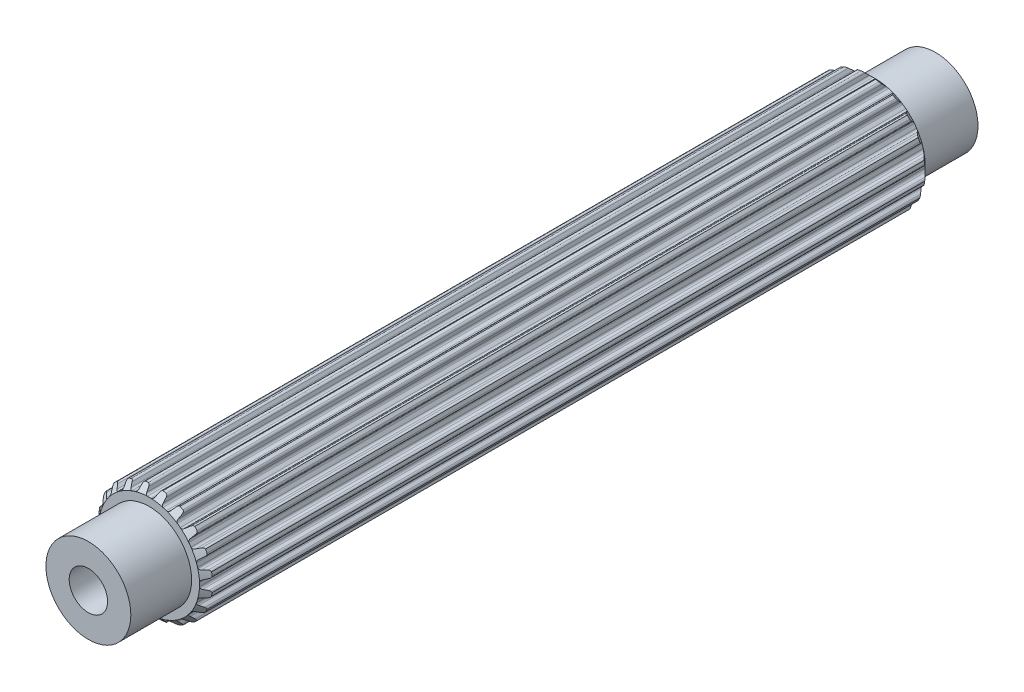
from build123d import *

# Parameters (mm, degrees)
BOSS_EXTRUDE1_DEPTH            = 21.37918
SKETCH2_R                      = 2.5019
BOSS_EXTRUDE2_DEPTH            = 24.96058
CUT_EXTRUDE1_REACH             = 26.961
SKETCH6_R                      = 1.1303
CUT_EXTRUDE1_DIRECTION_2_REACH = 26.961
SKETCH7_R                      = 1.1303
BOSS_EXTRUDE3_DEPTH            = 15.43558
BOSS_EXTRUDE3_DEPTH_BACK       = 15.43558


with BuildPart() as part:
    # Sketch1 → Boss-Extrude1 (new body, symmetric)
    with BuildSketch(Plane.XY):
        with BuildLine():
            Line((-0.106949245, 2.969874934), (0.106949245, 2.969874934))
            ThreePointArc((0.106949245, 2.969874934), (0.196343213, 2.986924176), (0.253739238, 3.057547504))
            Line((0.253739238, 3.057547504), (0.315888147, 3.237526941))
            ThreePointArc((0.315888147, 3.237526941), (0.359032156, 3.298322911), (0.4281449, 3.326269005))
            Line((0.4281449, 3.326269005), (0.620027588, 3.2937547))
            ThreePointArc((0.620027588, 3.2937547), (0.689621142, 3.24802576), (0.718272212, 3.169836791))
            Line((0.718272212, 3.169836791), (0.724389167, 2.979527391))
            ThreePointArc((0.724389167, 2.979527391), (0.750934762, 2.9040661), (0.816027049, 2.857568043))
            Line((0.816027049, 2.857568043), (1.019456602, 2.791469774))
            ThreePointArc((1.019456602, 2.791469774), (1.109743823, 2.780060312), (1.186154496, 2.829490741))
            Line((1.186154496, 2.829490741), (1.300878326, 2.981456288))
            ThreePointArc((1.300878326, 2.981456288), (1.360697704, 3.02594446), (1.435063648, 3.031165762))
            Line((1.435063648, 3.031165762), (1.607507455, 2.940947809))
            ThreePointArc((1.607507455, 2.940947809), (1.659563839, 2.875951412), (1.662650905, 2.792735615))
            Line((1.662650905, 2.792735615), (1.609659636, 2.609850378))
            ThreePointArc((1.609659636, 2.609850378), (1.611587176, 2.529879385), (1.659124931, 2.465542482))
            Line((1.659124931, 2.465542482), (1.832172444, 2.339816104))
            ThreePointArc((1.832172444, 2.339816104), (1.914514976, 2.301064775), (2.002460687, 2.32446371))
            Line((2.002460687, 2.32446371), (2.158529469, 2.433539921))
            ThreePointArc((2.158529469, 2.433539921), (2.229168681, 2.457365482), (2.301508367, 2.439350895))
            Line((2.301508367, 2.439350895), (2.437633293, 2.300260456))
            ThreePointArc((2.437633293, 2.300260456), (2.467056864, 2.222358901), (2.444277744, 2.14226202))
            Line((2.444277744, 2.14226202), (2.337365406, 1.984703026))
            ThreePointArc((2.337365406, 1.984703026), (2.314486209, 1.908050449), (2.339816104, 1.832172444))
            Line((2.339816104, 1.832172444), (2.465542482, 1.659124931))
            ThreePointArc((2.465542482, 1.659124931), (2.531880064, 1.596824985), (2.622752074, 1.591901975))
            Line((2.622752074, 1.591901975), (2.804888709, 1.64741171))
            ThreePointArc((2.804888709, 1.64741171), (2.879433095, 1.648242449), (2.942665411, 1.608755366))
            Line((2.942665411, 1.608755366), (3.0291466, 1.434407582))
            ThreePointArc((3.0291466, 1.434407582), (3.033057175, 1.351226417), (2.986641646, 1.282088892))
            Line((2.986641646, 1.282088892), (2.836273564, 1.165279113))
            ThreePointArc((2.836273564, 1.165279113), (2.790827206, 1.099448241), (2.791469774, 1.019456602))
            Line((2.791469774, 1.019456602), (2.857568043, 0.816027049))
            ThreePointArc((2.857568043, 0.816027049), (2.901407091, 0.736276839), (2.986310214, 0.703513784))
            Line((2.986310214, 0.703513784), (3.1766859, 0.700023363))
            ThreePointArc((3.1766859, 0.700023363), (3.247838536, 0.677777961), (3.295773863, 0.620683653))
            Line((3.295773863, 0.620683653), (3.324145932, 0.4281449))
            ThreePointArc((3.324145932, 0.4281449), (3.302160717, 0.347826477), (3.236652255, 0.29641597))
            Line((3.236652255, 0.29641597), (3.057547504, 0.231789562))
            ThreePointArc((3.057547504, 0.231789562), (2.993982591, 0.183224379), (2.969874934, 0.106949245))
            Line((2.969874934, 0.106949245), (2.969874934, -0.106949245))
            ThreePointArc((2.969874934, -0.106949245), (2.986924176, -0.196343213), (3.057547504, -0.253739238))
            Line((3.057547504, -0.253739238), (3.237526941, -0.315888147))
            ThreePointArc((3.237526941, -0.315888147), (3.298322911, -0.359032156), (3.326269005, -0.4281449))
            Line((3.326269005, -0.4281449), (3.2937547, -0.620027588))
            ThreePointArc((3.2937547, -0.620027588), (3.24802576, -0.689621142), (3.169836791, -0.718272212))
            Line((3.169836791, -0.718272212), (2.979527391, -0.724389167))
            ThreePointArc((2.979527391, -0.724389167), (2.9040661, -0.750934762), (2.857568043, -0.816027049))
            Line((2.857568043, -0.816027049), (2.791469774, -1.019456602))
            ThreePointArc((2.791469774, -1.019456602), (2.780060312, -1.109743823), (2.829490741, -1.186154496))
            Line((2.829490741, -1.186154496), (2.981456288, -1.300878326))
            ThreePointArc((2.981456288, -1.300878326), (3.02594446, -1.360697704), (3.031165762, -1.435063648))
            Line((3.031165762, -1.435063648), (2.940947809, -1.607507455))
            ThreePointArc((2.940947809, -1.607507455), (2.875951412, -1.659563839), (2.792735615, -1.662650905))
            Line((2.792735615, -1.662650905), (2.609850378, -1.609659636))
            ThreePointArc((2.609850378, -1.609659636), (2.529879385, -1.611587176), (2.465542482, -1.659124931))
            Line((2.465542482, -1.659124931), (2.339816104, -1.832172444))
            ThreePointArc((2.339816104, -1.832172444), (2.301064775, -1.914514976), (2.32446371, -2.002460687))
            Line((2.32446371, -2.002460687), (2.433539921, -2.158529469))
            ThreePointArc((2.433539921, -2.158529469), (2.457365482, -2.229168681), (2.439350895, -2.301508367))
            Line((2.439350895, -2.301508367), (2.300260456, -2.437633293))
            ThreePointArc((2.300260456, -2.437633293), (2.222358901, -2.467056864), (2.14226202, -2.444277744))
            Line((2.14226202, -2.444277744), (1.984703026, -2.337365406))
            ThreePointArc((1.984703026, -2.337365406), (1.908050449, -2.314486209), (1.832172444, -2.339816104))
            Line((1.832172444, -2.339816104), (1.659124931, -2.465542482))
            ThreePointArc((1.659124931, -2.465542482), (1.596824985, -2.531880064), (1.591901975, -2.622752074))
            Line((1.591901975, -2.622752074), (1.64741171, -2.804888709))
            ThreePointArc((1.64741171, -2.804888709), (1.648242449, -2.879433095), (1.608755366, -2.942665411))
            Line((1.608755366, -2.942665411), (1.434407582, -3.0291466))
            ThreePointArc((1.434407582, -3.0291466), (1.351226417, -3.033057175), (1.282088892, -2.986641646))
            Line((1.282088892, -2.986641646), (1.165279113, -2.836273564))
            ThreePointArc((1.165279113, -2.836273564), (1.099448241, -2.790827206), (1.019456602, -2.791469774))
            Line((1.019456602, -2.791469774), (0.816027049, -2.857568043))
            ThreePointArc((0.816027049, -2.857568043), (0.736276839, -2.901407091), (0.703513784, -2.986310214))
            Line((0.703513784, -2.986310214), (0.700023363, -3.1766859))
            ThreePointArc((0.700023363, -3.1766859), (0.677777961, -3.247838536), (0.620683653, -3.295773863))
            Line((0.620683653, -3.295773863), (0.4281449, -3.324145932))
            ThreePointArc((0.4281449, -3.324145932), (0.347826477, -3.302160717), (0.29641597, -3.236652255))
            Line((0.29641597, -3.236652255), (0.231789562, -3.057547504))
            ThreePointArc((0.231789562, -3.057547504), (0.183224379, -2.993982591), (0.106949245, -2.969874934))
            Line((0.106949245, -2.969874934), (-0.106949245, -2.969874934))
            ThreePointArc((-0.106949245, -2.969874934), (-0.196343213, -2.986924176), (-0.253739238, -3.057547504))
            Line((-0.253739238, -3.057547504), (-0.315888147, -3.237526941))
            ThreePointArc((-0.315888147, -3.237526941), (-0.359032156, -3.298322911), (-0.4281449, -3.326269005))
            Line((-0.4281449, -3.326269005), (-0.620027588, -3.2937547))
            ThreePointArc((-0.620027588, -3.2937547), (-0.689621142, -3.24802576), (-0.718272212, -3.169836791))
            Line((-0.718272212, -3.169836791), (-0.724389167, -2.979527391))
            ThreePointArc((-0.724389167, -2.979527391), (-0.750934762, -2.9040661), (-0.816027049, -2.857568043))
            Line((-0.816027049, -2.857568043), (-1.019456602, -2.791469774))
            ThreePointArc((-1.019456602, -2.791469774), (-1.109743823, -2.780060312), (-1.186154496, -2.829490741))
            Line((-1.186154496, -2.829490741), (-1.300878326, -2.981456288))
            ThreePointArc((-1.300878326, -2.981456288), (-1.360697704, -3.02594446), (-1.435063648, -3.031165762))
            Line((-1.435063648, -3.031165762), (-1.607507455, -2.940947809))
            ThreePointArc((-1.607507455, -2.940947809), (-1.659563839, -2.875951412), (-1.662650905, -2.792735615))
            Line((-1.662650905, -2.792735615), (-1.609659636, -2.609850378))
            ThreePointArc((-1.609659636, -2.609850378), (-1.611587176, -2.529879385), (-1.659124931, -2.465542482))
            Line((-1.659124931, -2.465542482), (-1.832172444, -2.339816104))
            ThreePointArc((-1.832172444, -2.339816104), (-1.914514976, -2.301064775), (-2.002460687, -2.32446371))
            Line((-2.002460687, -2.32446371), (-2.158529469, -2.433539921))
            ThreePointArc((-2.158529469, -2.433539921), (-2.229168681, -2.457365482), (-2.301508367, -2.439350895))
            Line((-2.301508367, -2.439350895), (-2.437633293, -2.300260456))
            ThreePointArc((-2.437633293, -2.300260456), (-2.467056864, -2.222358901), (-2.444277744, -2.14226202))
            Line((-2.444277744, -2.14226202), (-2.337365406, -1.984703026))
            ThreePointArc((-2.337365406, -1.984703026), (-2.314486209, -1.908050449), (-2.339816104, -1.832172444))
            Line((-2.339816104, -1.832172444), (-2.465542482, -1.659124931))
            ThreePointArc((-2.465542482, -1.659124931), (-2.531880064, -1.596824985), (-2.622752074, -1.591901975))
            Line((-2.622752074, -1.591901975), (-2.804888709, -1.64741171))
            ThreePointArc((-2.804888709, -1.64741171), (-2.879433095, -1.648242449), (-2.942665411, -1.608755366))
            Line((-2.942665411, -1.608755366), (-3.0291466, -1.434407582))
            ThreePointArc((-3.0291466, -1.434407582), (-3.033057175, -1.351226417), (-2.986641646, -1.282088892))
            Line((-2.986641646, -1.282088892), (-2.836273564, -1.165279113))
            ThreePointArc((-2.836273564, -1.165279113), (-2.790827206, -1.099448241), (-2.791469774, -1.019456602))
            Line((-2.791469774, -1.019456602), (-2.857568043, -0.816027049))
            ThreePointArc((-2.857568043, -0.816027049), (-2.901407091, -0.736276839), (-2.986310214, -0.703513784))
            Line((-2.986310214, -0.703513784), (-3.1766859, -0.700023363))
            ThreePointArc((-3.1766859, -0.700023363), (-3.247838536, -0.677777961), (-3.295773863, -0.620683653))
            Line((-3.295773863, -0.620683653), (-3.324145932, -0.4281449))
            ThreePointArc((-3.324145932, -0.4281449), (-3.302160717, -0.347826477), (-3.236652255, -0.29641597))
            Line((-3.236652255, -0.29641597), (-3.057547504, -0.231789562))
            ThreePointArc((-3.057547504, -0.231789562), (-2.993982591, -0.183224379), (-2.969874934, -0.106949245))
            Line((-2.969874934, -0.106949245), (-2.969874934, 0.106949245))
            ThreePointArc((-2.969874934, 0.106949245), (-2.986924176, 0.196343213), (-3.057547504, 0.253739238))
            Line((-3.057547504, 0.253739238), (-3.237526941, 0.315888147))
            ThreePointArc((-3.237526941, 0.315888147), (-3.298322911, 0.359032156), (-3.326269005, 0.4281449))
            Line((-3.326269005, 0.4281449), (-3.2937547, 0.620027588))
            ThreePointArc((-3.2937547, 0.620027588), (-3.24802576, 0.689621142), (-3.169836791, 0.718272212))
            Line((-3.169836791, 0.718272212), (-2.979527391, 0.724389167))
            ThreePointArc((-2.979527391, 0.724389167), (-2.9040661, 0.750934762), (-2.857568043, 0.816027049))
            Line((-2.857568043, 0.816027049), (-2.791469774, 1.019456602))
            ThreePointArc((-2.791469774, 1.019456602), (-2.780060312, 1.109743823), (-2.829490741, 1.186154496))
            Line((-2.829490741, 1.186154496), (-2.981456288, 1.300878326))
            ThreePointArc((-2.981456288, 1.300878326), (-3.02594446, 1.360697704), (-3.031165762, 1.435063648))
            Line((-3.031165762, 1.435063648), (-2.940947809, 1.607507455))
            ThreePointArc((-2.940947809, 1.607507455), (-2.875951412, 1.659563839), (-2.792735615, 1.662650905))
            Line((-2.792735615, 1.662650905), (-2.609850378, 1.609659636))
            ThreePointArc((-2.609850378, 1.609659636), (-2.529879385, 1.611587176), (-2.465542482, 1.659124931))
            Line((-2.465542482, 1.659124931), (-2.339816104, 1.832172444))
            ThreePointArc((-2.339816104, 1.832172444), (-2.301064775, 1.914514976), (-2.32446371, 2.002460687))
            Line((-2.32446371, 2.002460687), (-2.433539921, 2.158529469))
            ThreePointArc((-2.433539921, 2.158529469), (-2.457365482, 2.229168681), (-2.439350895, 2.301508367))
            Line((-2.439350895, 2.301508367), (-2.300260456, 2.437633293))
            ThreePointArc((-2.300260456, 2.437633293), (-2.222358901, 2.467056864), (-2.14226202, 2.444277744))
            Line((-2.14226202, 2.444277744), (-1.984703026, 2.337365406))
            ThreePointArc((-1.984703026, 2.337365406), (-1.908050449, 2.314486209), (-1.832172444, 2.339816104))
            Line((-1.832172444, 2.339816104), (-1.659124931, 2.465542482))
            ThreePointArc((-1.659124931, 2.465542482), (-1.596824985, 2.531880064), (-1.591901975, 2.622752074))
            Line((-1.591901975, 2.622752074), (-1.64741171, 2.804888709))
            ThreePointArc((-1.64741171, 2.804888709), (-1.648242449, 2.879433095), (-1.608755366, 2.942665411))
            Line((-1.608755366, 2.942665411), (-1.434407582, 3.0291466))
            ThreePointArc((-1.434407582, 3.0291466), (-1.351226417, 3.033057175), (-1.282088892, 2.986641646))
            Line((-1.282088892, 2.986641646), (-1.165279113, 2.836273564))
            ThreePointArc((-1.165279113, 2.836273564), (-1.099448241, 2.790827206), (-1.019456602, 2.791469774))
            Line((-1.019456602, 2.791469774), (-0.816027049, 2.857568043))
            ThreePointArc((-0.816027049, 2.857568043), (-0.736276839, 2.901407091), (-0.703513784, 2.986310214))
            Line((-0.703513784, 2.986310214), (-0.700023363, 3.1766859))
            ThreePointArc((-0.700023363, 3.1766859), (-0.677777961, 3.247838536), (-0.620683653, 3.295773863))
            Line((-0.620683653, 3.295773863), (-0.4281449, 3.324145932))
            ThreePointArc((-0.4281449, 3.324145932), (-0.347826477, 3.302160717), (-0.29641597, 3.236652255))
            Line((-0.29641597, 3.236652255), (-0.231789562, 3.057547504))
            ThreePointArc((-0.231789562, 3.057547504), (-0.183224379, 2.993982591), (-0.106949245, 2.969874934))
        make_face()
    extrude(amount=BOSS_EXTRUDE1_DEPTH, both=True)

    # Sketch2 → Boss-Extrude2 (add, symmetric)
    with BuildSketch(Plane.XY):
        Circle(SKETCH2_R)
    extrude(amount=BOSS_EXTRUDE2_DEPTH, both=True)

    # Sketch3 → Cut-Revolve1 (revolve, cut)
    with BuildSketch(Plane(origin=(0, 0, 0), x_dir=(0, 0, -1), z_dir=(1, 0, 0))):
        Polygon((-20.247955505, 4.101099429), (-21.37918, 2.969874934), (-21.37918, 4.101099429), align=None)
        Polygon((21.37918, 18.093049155), (21.37918, 2.969874934), (13.817592889, 10.531462045), align=None)
    revolve(axis=Axis((0, 0, 14.360793934), (0, 0, -1)), mode=Mode.SUBTRACT)

    # Cut-Extrude1: up to this face of the body (flat: up to its plane)
    cut_extrude1_end = Plane(part.part.faces().sort_by_distance((0, 0, -24.96058))[0])
    # Sketch6 → Cut-Extrude1 (cut, up to the picked face)
    with BuildSketch(Plane.XY, mode=Mode.PRIVATE) as cut_extrude1_sk1:
        Circle(SKETCH6_R)
    cut_extrude1_tool1 = split(extrude(cut_extrude1_sk1.sketch, amount=-CUT_EXTRUDE1_REACH, mode=Mode.PRIVATE), bisect_by=cut_extrude1_end, keep=Keep.BOTH, mode=Mode.PRIVATE)
    add(cut_extrude1_tool1.solids().sort_by_distance((0, 0, 0))[0], mode=Mode.SUBTRACT)

    # Cut-Extrude1 direction 2: up to this face of the body (flat: up to its plane)
    cut_extrude1_direction_2_end = Plane(part.part.faces().sort_by_distance((0, 0, 24.96058))[0])
    # Sketch6 → Cut-Extrude1 direction 2 (cut, up to the picked face)
    with BuildSketch(Plane.XY, mode=Mode.PRIVATE) as cut_extrude1_direction_2_sk1:
        Circle(SKETCH6_R)
    cut_extrude1_direction_2_tool1 = split(extrude(cut_extrude1_direction_2_sk1.sketch, amount=CUT_EXTRUDE1_DIRECTION_2_REACH, mode=Mode.PRIVATE), bisect_by=cut_extrude1_direction_2_end, keep=Keep.BOTH, mode=Mode.PRIVATE)
    add(cut_extrude1_direction_2_tool1.solids().sort_by_distance((0, 0, 0))[0], mode=Mode.SUBTRACT)

    # Sketch7 → Boss-Extrude3 (add, two sides)
    with BuildSketch(Plane.XY) as boss_extrude3_sk:
        Circle(SKETCH7_R)
    extrude(amount=BOSS_EXTRUDE3_DEPTH)
    extrude(boss_extrude3_sk.sketch, amount=-BOSS_EXTRUDE3_DEPTH_BACK)


solid = part.part
